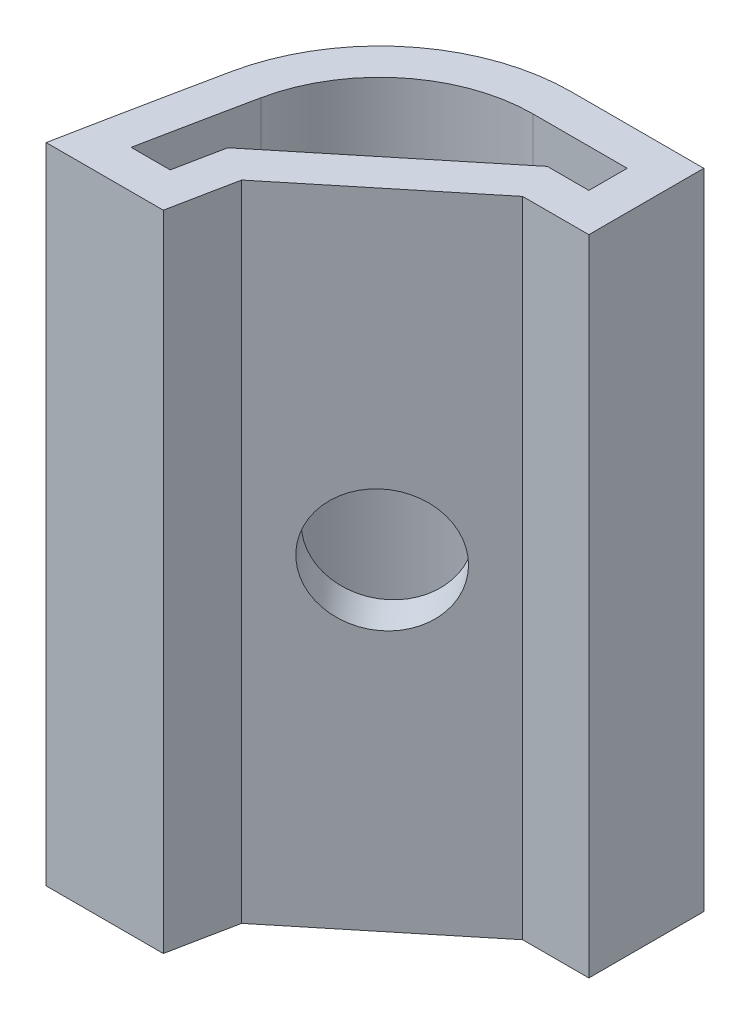
from build123d import *

# Parameters (mm, degrees)
BOSS_EXTRUDE1_DEPTH = 16.8
SKETCH3_R           = 1.602221917
CUT_EXTRUDE2_DEPTH  = 1


with BuildPart() as part:
    # Sketch1 → Boss-Extrude1 (new body)
    with BuildSketch(Plane(origin=(0, 0, 0), x_dir=(1, 0, 0), z_dir=(0, 1, 0))):
        with BuildLine():
            Line((-4.627081214, -3.973073539), (-1.569860328, -3.973073539))
            ThreePointArc((-1.569860328, -3.973073539), (-1.400678587, -3.120671939), (-1.229309949, -2.268707303))
            Line((-1.229309949, -2.268707303), (2.8066913, 1.026926461))
            Line((2.8066913, 1.026926461), (4.535241357, 1.026926461))
            Line((4.535241357, 1.026926461), (4.535241357, 4.026926461))
            Line((4.535241357, 4.026926461), (1.078141243, 4.026926461))
            ThreePointArc((1.078141243, 4.026926461), (-2.077248816, 2.905523317), (-3.817253142, 0.044331891))
            ThreePointArc((-3.817253142, 0.044331891), (-4.228191177, -1.963156507), (-4.627081214, -3.973073539))
        make_face()
        with BuildLine():
            Line((-3.410627534, -2.973073539), (-2.390949988, -2.973073539))
            ThreePointArc((-2.390949988, -2.973073539), (-2.265209784, -2.346372679), (-2.138290376, -1.719909567))
            Line((-2.138290376, -1.719909567), (2.450276186, 2.026926461))
            Line((2.450276186, 2.026926461), (3.535241357, 2.026926461))
            Line((3.535241357, 2.026926461), (3.535241357, 3.026926461))
            Line((3.535241357, 3.026926461), (1.078141243, 3.026926461))
            ThreePointArc((1.078141243, 3.026926461), (-1.446170804, 2.129803946), (-2.838174265, -0.159149195))
            ThreePointArc((-2.838174265, -0.159149195), (-3.127366046, -1.56550815), (-3.410627534, -2.973073539))
        make_face(mode=Mode.SUBTRACT)
    extrude(amount=BOSS_EXTRUDE1_DEPTH)

    # Sketch3 → Cut-Extrude2 (cut)
    with BuildSketch(Plane(origin=(0.619682886, 0, 0.758895279), x_dir=(0.774572925, 0, -0.632484612), z_dir=(0.632484612, 0, 0.774572925))):
        with Locations((0.218194806, 8.4)):
            Circle(SKETCH3_R)
    extrude(amount=-CUT_EXTRUDE2_DEPTH, mode=Mode.SUBTRACT)


solid = part.part
